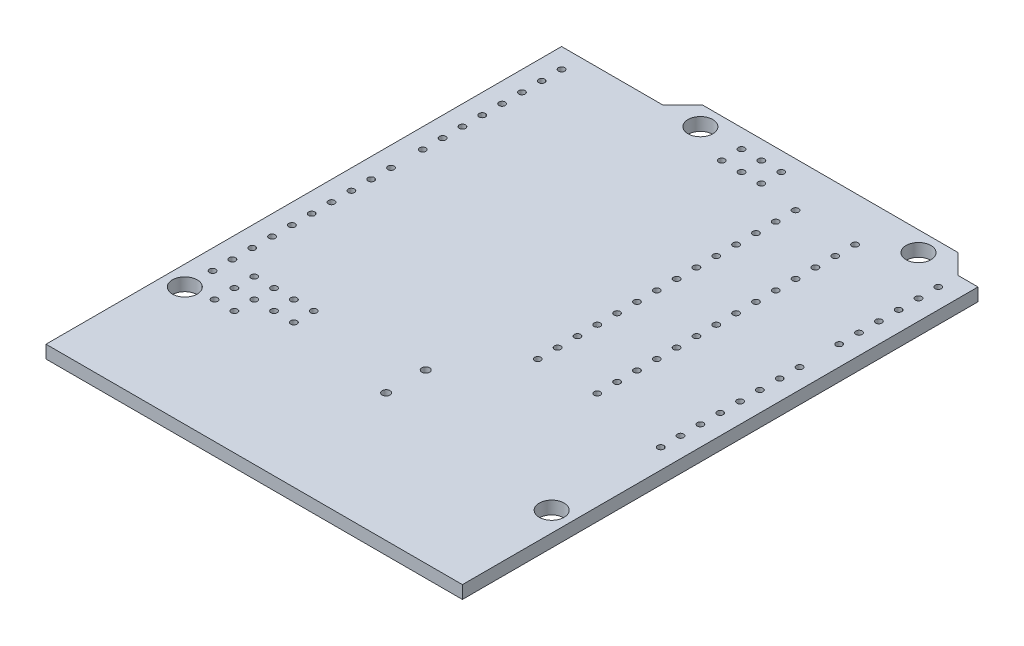
from build123d import *

# Parameters (mm, degrees)
SKETCH1_R           = 1.5875
BOSS_EXTRUDE1_DEPTH = 1.65
SKETCH2_R           = 0.4
CUT_EXTRUDE1_DEPTH  = 1.65
SKETCH3_R           = 0.4
CUT_EXTRUDE2_DEPTH  = 1.65
LPATTERN1_COUNT     = 15
LPATTERN1_PITCH     = 2.54
SKETCH4_R           = 0.4
CUT_EXTRUDE3_DEPTH  = 1.65
LPATTERN2_COUNT     = 10
LPATTERN2_PITCH     = 2.54
LPATTERN3_COUNT     = 8
LPATTERN3_PITCH     = 2.54
SKETCH5_R           = 0.4
SKETCH5_R_2         = 0.5
CUT_EXTRUDE4_DEPTH  = 10
SKETCH6_R           = 0.4
CUT_EXTRUDE5_DEPTH  = 10


with BuildPart() as part:
    # Sketch1 → Boss-Extrude1 (new body)
    with BuildSketch(Plane(origin=(0, 0, 0), x_dir=(1, 0, 0), z_dir=(0, 1, 0))):
        Polygon((0, 0), (-53.34, 0), (-53.34, 66.04), (-40.386, 66.04), (-37.846, 68.58), (-5.08, 68.58), (-2.54, 66.04), (0, 66.04), align=None)
        with Locations((-7.62, 66.04)):
            Circle(SKETCH1_R, mode=Mode.SUBTRACT)
        with Locations((-35.56, 66.04)):
            Circle(SKETCH1_R, mode=Mode.SUBTRACT)
        with Locations((-2.54, 13.97)):
            Circle(SKETCH1_R, mode=Mode.SUBTRACT)
        with Locations((-50.8, 15.24)):
            Circle(SKETCH1_R, mode=Mode.SUBTRACT)
    extrude(amount=-BOSS_EXTRUDE1_DEPTH)

    # Sketch2 → Cut-Extrude1 (cut)
    with BuildSketch(Plane(origin=(0, 0, 0), x_dir=(1, 0, 0), z_dir=(0, 1, 0))):
        with Locations((-2.54, 27.94)):
            Circle(SKETCH2_R)
    cut_extrude1 = extrude(amount=-CUT_EXTRUDE1_DEPTH, mode=Mode.SUBTRACT)

    # Sketch3 → Cut-Extrude2 (cut)
    with BuildSketch(Plane(origin=(0, 0, 0), x_dir=(1, 0, 0), z_dir=(0, 1, 0))):
        with Locations((-50.8, 18.796)):
            Circle(SKETCH3_R)
    cut_extrude2 = extrude(amount=-CUT_EXTRUDE2_DEPTH, mode=Mode.SUBTRACT)

    # LPattern1: Cut-Extrude1 ×15, 1 skipped
    with Locations(*[(0, 0, -i * LPATTERN1_PITCH) for i in range(1, LPATTERN1_COUNT) if i not in (8,)]):
        add(cut_extrude1, mode=Mode.SUBTRACT)

    # Sketch4 → Cut-Extrude3 (cut)
    with BuildSketch(Plane(origin=(0, 0, 0), x_dir=(1, 0, 0), z_dir=(0, 1, 0))):
        with Locations((-50.8, 45.72)):
            Circle(SKETCH4_R)
    cut_extrude3 = extrude(amount=-CUT_EXTRUDE3_DEPTH, mode=Mode.SUBTRACT)

    # LPattern2: Cut-Extrude2 ×10
    with Locations(*[(0, 0, -i * LPATTERN2_PITCH) for i in range(1, LPATTERN2_COUNT)]):
        add(cut_extrude2, mode=Mode.SUBTRACT)

    # LPattern3: Cut-Extrude3 ×8
    with Locations(*[(0, 0, -i * LPATTERN3_PITCH) for i in range(1, LPATTERN3_COUNT)]):
        add(cut_extrude3, mode=Mode.SUBTRACT)

    # Sketch5 → Cut-Extrude4 (cut)
    with BuildSketch(Plane(origin=(0, 0, 0), x_dir=(1, 0, 0), z_dir=(0, 1, 0))):
        with Locations((-30.43, 66.18)):
            Circle(SKETCH5_R)
        with Locations((-27.89, 66.18)):
            Circle(SKETCH5_R)
        with Locations((-25.35, 66.18)):
            Circle(SKETCH5_R)
        with Locations((-25.35, 63.64)):
            Circle(SKETCH5_R)
        with Locations((-27.89, 63.64)):
            Circle(SKETCH5_R)
        with Locations((-30.43, 63.64)):
            Circle(SKETCH5_R)
        with Locations((-47.498, 15.748)):
            Circle(SKETCH5_R)
        with Locations((-47.498, 18.288)):
            Circle(SKETCH5_R)
        with Locations((-47.498, 20.828)):
            Circle(SKETCH5_R)
        with Locations((-44.958, 20.828)):
            Circle(SKETCH5_R)
        with Locations((-44.958, 18.288)):
            Circle(SKETCH5_R)
        with Locations((-44.958, 15.748)):
            Circle(SKETCH5_R)
        with Locations((-42.418, 18.288)):
            Circle(SKETCH5_R)
        with Locations((-42.418, 20.828)):
            Circle(SKETCH5_R)
        with Locations((-39.878, 20.828)):
            Circle(SKETCH5_R)
        with Locations((-39.878, 18.288)):
            Circle(SKETCH5_R)
        with Locations((-26.162, 21.463)):
            Circle(SKETCH5_R_2)
        with Locations((-26.162, 16.383)):
            Circle(SKETCH5_R_2)
    extrude(amount=-CUT_EXTRUDE4_DEPTH, mode=Mode.SUBTRACT)

    # Sketch6 → Cut-Extrude5 (cut)
    with BuildSketch(Plane(origin=(0, 0, 0), x_dir=(1, 0, 0), z_dir=(0, 1, 0))):
        with Locations((-20.193, 29.845)):
            Circle(SKETCH6_R)
        with Locations((-12.573, 29.845)):
            Circle(SKETCH6_R)
        with Locations((-20.193, 32.385)):
            Circle(SKETCH6_R)
        with Locations((-12.573, 32.385)):
            Circle(SKETCH6_R)
        with Locations((-20.193, 34.925)):
            Circle(SKETCH6_R)
        with Locations((-12.573, 34.925)):
            Circle(SKETCH6_R)
        with Locations((-20.193, 37.465)):
            Circle(SKETCH6_R)
        with Locations((-12.573, 37.465)):
            Circle(SKETCH6_R)
        with Locations((-20.193, 40.005)):
            Circle(SKETCH6_R)
        with Locations((-12.573, 40.005)):
            Circle(SKETCH6_R)
        with Locations((-20.193, 42.545)):
            Circle(SKETCH6_R)
        with Locations((-12.573, 42.545)):
            Circle(SKETCH6_R)
        with Locations((-20.193, 45.085)):
            Circle(SKETCH6_R)
        with Locations((-12.573, 45.085)):
            Circle(SKETCH6_R)
        with Locations((-20.193, 47.625)):
            Circle(SKETCH6_R)
        with Locations((-12.573, 47.625)):
            Circle(SKETCH6_R)
        with Locations((-20.193, 50.165)):
            Circle(SKETCH6_R)
        with Locations((-12.573, 50.165)):
            Circle(SKETCH6_R)
        with Locations((-20.193, 52.705)):
            Circle(SKETCH6_R)
        with Locations((-12.573, 52.705)):
            Circle(SKETCH6_R)
        with Locations((-20.193, 55.245)):
            Circle(SKETCH6_R)
        with Locations((-12.573, 55.245)):
            Circle(SKETCH6_R)
        with Locations((-20.193, 57.785)):
            Circle(SKETCH6_R)
        with Locations((-12.573, 57.785)):
            Circle(SKETCH6_R)
        with Locations((-20.193, 60.325)):
            Circle(SKETCH6_R)
        with Locations((-12.573, 60.325)):
            Circle(SKETCH6_R)
        with Locations((-20.193, 62.865)):
            Circle(SKETCH6_R)
        with Locations((-12.573, 62.865)):
            Circle(SKETCH6_R)
    extrude(amount=-CUT_EXTRUDE5_DEPTH, mode=Mode.SUBTRACT)


solid = part.part
